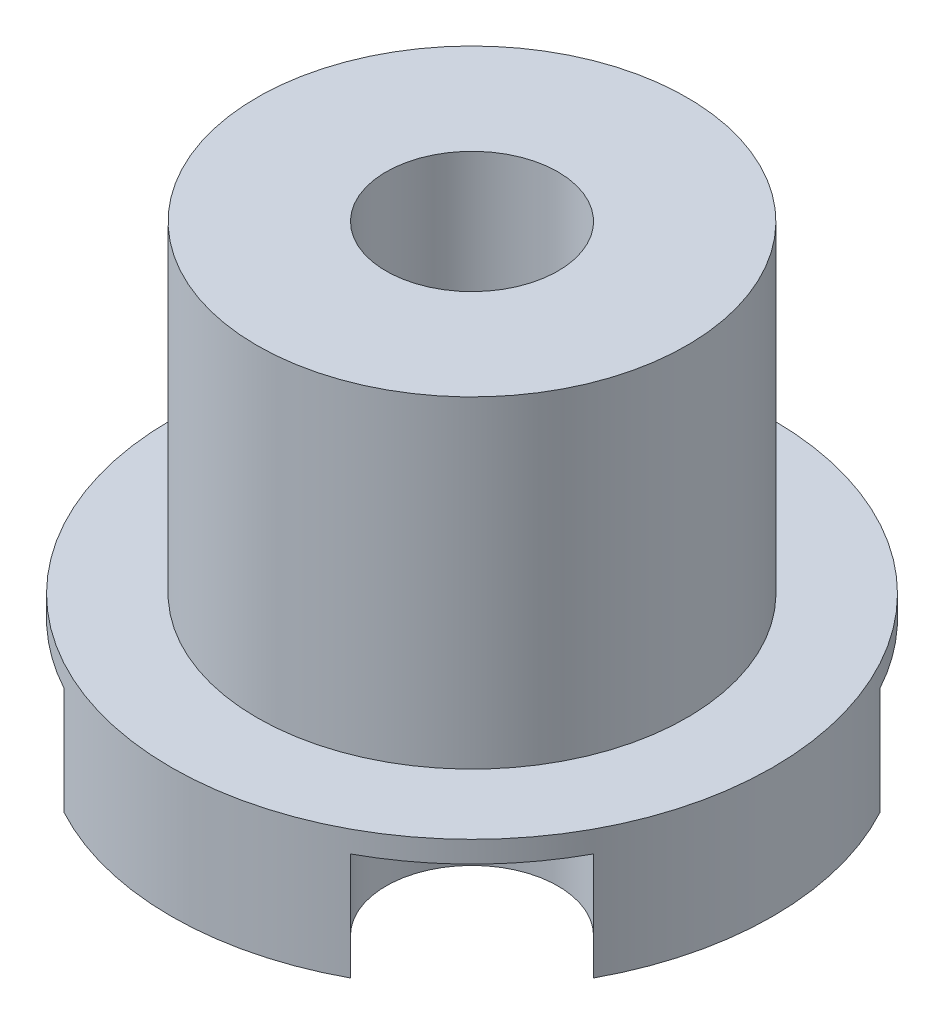
from build123d import *

# Parameters (mm, degrees)
SKETCH_1_R               = 14
EXTRUDE_1_DEPTH          = 6
SKETCH_2_R               = 10
EXTRUDE_2_DEPTH          = 15
SKETCH_3_R               = 1
SKETCH_3_R_2             = 4
CUT_EXTRUDE_1_DEPTH      = 5
CUT_EXTRUDE_2_DEPTH      = 5
PATTERN_CIRCULAR_1_COUNT = 4
SKETCH_5_R               = 4
CUT_EXTRUDE_3_DEPTH      = 22


with BuildPart() as part:
    # Эскиз1 → Бобышка-Вытянуть1 (new body)
    with BuildSketch(Plane(origin=(0, 0, 0), x_dir=(1, 0, 0), z_dir=(0, 1, 0))):
        Circle(SKETCH_1_R)
    extrude(amount=EXTRUDE_1_DEPTH)

    # Эскиз2 → Бобышка-Вытянуть2 (add)
    with BuildSketch(Plane(origin=(0, 6, 0), x_dir=(1, 0, 0), z_dir=(0, 1, 0))):
        Circle(SKETCH_2_R)
    extrude(amount=EXTRUDE_2_DEPTH)

    # Эскиз3 → Вырез-Вытянуть1 (cut)
    with BuildSketch(Plane.XZ):
        with Locations((-8, 0)):
            Circle(SKETCH_3_R)
        with Locations((8, 0)):
            Circle(SKETCH_3_R)
        with Locations((0, 9.5)):
            Circle(SKETCH_3_R)
        with Locations((0, -9.5)):
            Circle(SKETCH_3_R)
        with Locations((-7.778174593, 7.778174593)):
            Circle(SKETCH_3_R_2)
        with Locations((7.778174593, 7.778174593)):
            Circle(SKETCH_3_R_2)
        with Locations((7.778174593, -7.778174593)):
            Circle(SKETCH_3_R_2)
        with Locations((-7.778174593, -7.778174593)):
            Circle(SKETCH_3_R_2)
    extrude(amount=-CUT_EXTRUDE_1_DEPTH, mode=Mode.SUBTRACT)

    # Эскиз4 → Вырез-Вытянуть2 (cut)
    with BuildSketch(Plane.XZ):
        Polygon((-4.949747468, 10.606601718), (-10.606601718, 4.949747468), (-15.333238313, 9.676384064), (-9.676384064, 15.333238313), align=None)
    cut_extrude_2 = extrude(amount=-CUT_EXTRUDE_2_DEPTH, mode=Mode.SUBTRACT)

    # Круговой массив1: Вырез-Вытянуть2 ×4 about axis
    pattern_circular_1_axis = Axis((0, 0, 0), (0, 1, 0))
    for i in range(1, PATTERN_CIRCULAR_1_COUNT):
        add(cut_extrude_2.rotate(pattern_circular_1_axis, i * 360 / PATTERN_CIRCULAR_1_COUNT), mode=Mode.SUBTRACT)

    # Эскиз5 → Вырез-Вытянуть3 (cut, through all)
    with BuildSketch(Plane.XZ):
        Circle(SKETCH_5_R)
    extrude(amount=-CUT_EXTRUDE_3_DEPTH, mode=Mode.SUBTRACT)


solid = part.part
